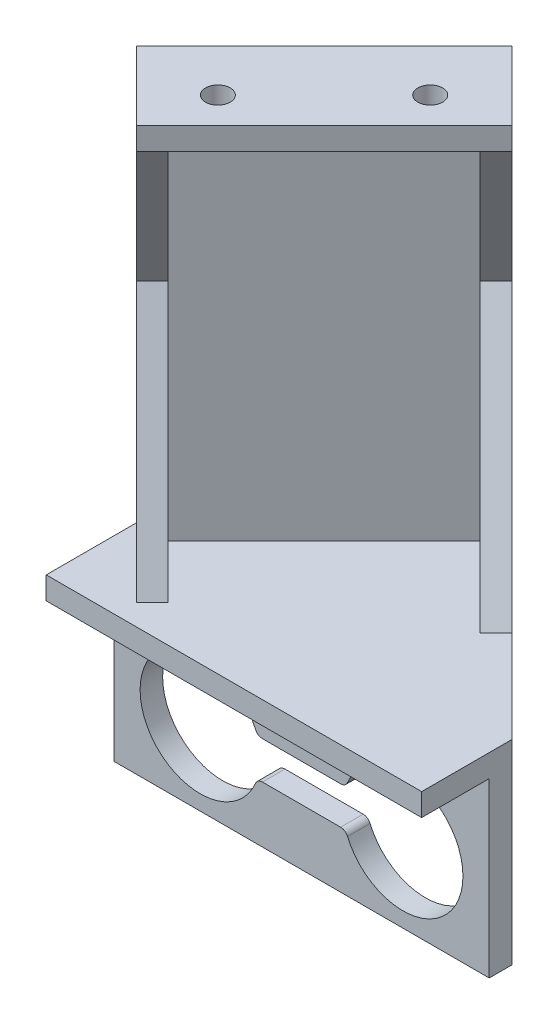
from build123d import *

# Parameters (mm, degrees)
SKETCH_1_W          = 50
SKETCH_1_H          = 20
EXTRUDE_1_DEPTH     = 3
SKETCH_2_W          = 50
SKETCH_2_H          = 12
EXTRUDE_2_DEPTH     = 6
SKETCH_5_W          = 50
SKETCH_5_H          = 9
CUT_EXTRUDE_2_DEPTH = 3
EXTRUDE_3_DEPTH     = 3
EXTRUDE_4_DEPTH     = 55
SKETCH_12_W         = 32.35533906
SKETCH_12_H         = 3
EXTRUDE_6_DEPTH     = 10
EXTRUDE_7_DEPTH     = 3
EXTRUDE_8_DEPTH     = 3
SKETCH_15_R         = 1.65
CUT_EXTRUDE_3_DEPTH = 3


with BuildPart() as part:
    # 草图1 → 凸台-拉伸1 (new body)
    with BuildSketch(Plane.XY):
        Rectangle(SKETCH_1_W, SKETCH_1_H)
        with BuildLine():
            Line((-5.208438024, 2.5), (5.208438024, 2.5))
            ThreePointArc((5.208438024, 2.5), (5.761208823, 2.666666667), (6.129722688, 3.111111111))
            ThreePointArc((6.129722688, 3.111111111), (21.5, 0), (6.129722688, -3.111111111))
            ThreePointArc((6.129722688, -3.111111111), (5.761208823, -2.666666667), (5.208438024, -2.5))
            Line((5.208438024, -2.5), (-5.208438024, -2.5))
            ThreePointArc((-5.208438024, -2.5), (-5.761208823, -2.666666667), (-6.129722688, -3.111111111))
            ThreePointArc((-6.129722688, -3.111111111), (-21.5, 0), (-6.129722688, 3.111111111))
            ThreePointArc((-6.129722688, 3.111111111), (-5.761208823, 2.666666667), (-5.208438024, 2.5))
        make_face(mode=Mode.SUBTRACT)
        with BuildLine():
            Line((3.25, 5.5), (-3.25, 5.5))
            ThreePointArc((-3.25, 5.5), (-5, 7.25), (-3.25, 9))
            Line((-3.25, 9), (3.25, 9))
            ThreePointArc((3.25, 9), (5, 7.25), (3.25, 5.5))
        make_face(mode=Mode.SUBTRACT)
    extrude(amount=EXTRUDE_1_DEPTH)

    # 草图2 → 凸台-拉伸2 (add)
    with BuildSketch(Plane(origin=(0, 10, 0), x_dir=(1, 0, 0), z_dir=(0, 1, 0))):
        with Locations((0, -6)):
            Rectangle(SKETCH_2_W, SKETCH_2_H)
    extrude(amount=EXTRUDE_2_DEPTH)

    # 草图5 → 切除-拉伸2 (cut)
    with BuildSketch(Plane.XZ.offset(-10)):
        with Locations((0, 7.5)):
            Rectangle(SKETCH_5_W, SKETCH_5_H)
    extrude(amount=-CUT_EXTRUDE_2_DEPTH, mode=Mode.SUBTRACT)

    # 草图9 → 凸台-拉伸3 (add)
    with BuildSketch(Plane(origin=(0, 16, 0), x_dir=(1, 0, 0), z_dir=(0, 1, 0))):
        Polygon((25, 0), (0, 25), (-25, 0), align=None)
    extrude(amount=-EXTRUDE_3_DEPTH)

    # 草图11 → 凸台-拉伸4 (add)
    with BuildSketch(Plane(origin=(0, 16, 0), x_dir=(1, 0, 0), z_dir=(0, 1, 0))):
        Polygon((0, 25), (2.121320344, 22.878679656), (-22.878679656, -2.121320344), (-25, 0), align=None)
    extrude(amount=EXTRUDE_4_DEPTH)

    # 草图12 → 凸台-拉伸6 (add)
    with BuildSketch(Plane(origin=(-10.378679656, 0, -10.378679656), x_dir=(0.707106781, 0, -0.707106781), z_dir=(0.707106781, 0, 0.707106781))):
        with Locations((-1.5, 69.5)):
            Rectangle(SKETCH_12_W, SKETCH_12_H)
    extrude(amount=EXTRUDE_6_DEPTH)

    # 草图13 → 凸台-拉伸7 (add)
    with BuildSketch(Plane(origin=(12.5, 0, -12.5), x_dir=(-0.707106781, 0, -0.707106781), z_dir=(0.707106781, 0, -0.707106781))):
        Polygon((14.67766953, 16), (14.67766953, 46), (-0.32233047, 16), align=None)
        Polygon((14.67766953, 46), (14.67766953, 71), (4.67766953, 71), (4.67766953, 68), align=None)
    extrude(amount=-EXTRUDE_7_DEPTH)

    # 草图14 → 凸台-拉伸8 (add)
    with BuildSketch(Plane(origin=(-12.5, 0, 12.5), x_dir=(0.707106781, 0, 0.707106781), z_dir=(-0.707106781, 0, 0.707106781))):
        Polygon((-14.67766953, 46), (-14.67766953, 16), (-4.67766953, 16), align=None)
        Polygon((-14.67766953, 68), (-14.67766953, 46), (-4.67766953, 68), align=None)
    extrude(amount=-EXTRUDE_8_DEPTH)

    # 草图15 → 切除-拉伸3 (cut)
    with BuildSketch(Plane.XZ.offset(-68)):
        with Locations((0.227922061, -13.914213562)):
            Circle(SKETCH_15_R)
        with Locations((-13.914213562, 0.227922061)):
            Circle(SKETCH_15_R)
    extrude(amount=-CUT_EXTRUDE_3_DEPTH, mode=Mode.SUBTRACT)


solid = part.part
